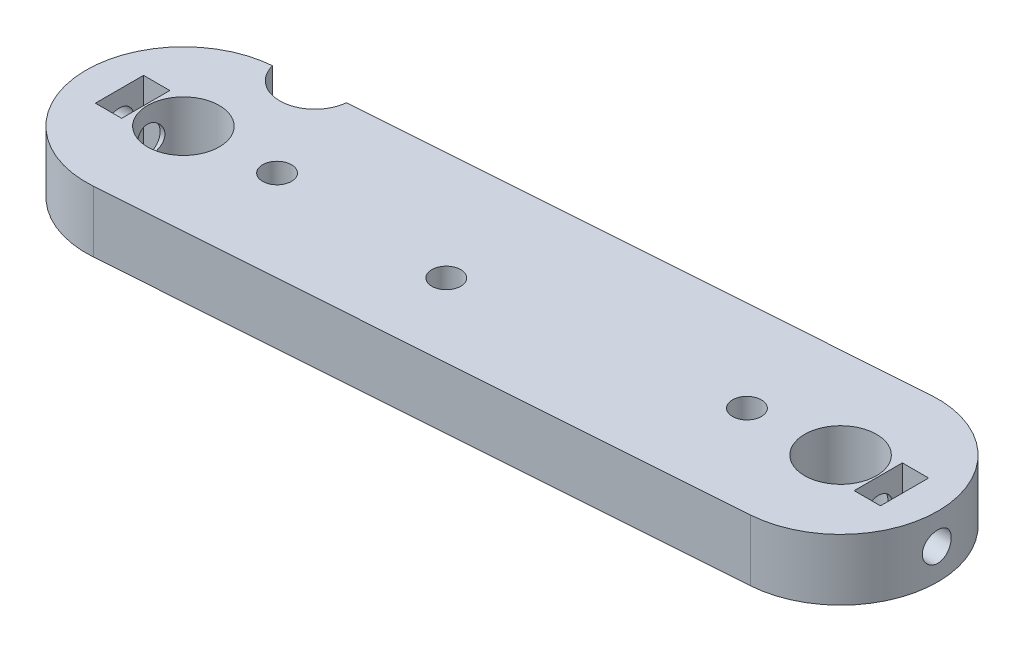
from build123d import *

# Parameters (mm, degrees)
ESBO_O2_R                  = 4.1
ESBO_O2_R_2                = 1.65
ESBO_O2_W                  = 3
ESBO_O2_H                  = 5.5
RESSALTO_EXTRUS_O1_DEPTH   = 7
ESBO_O3_W                  = 117.766713874
ESBO_O3_H                  = 105.694955048
CORTE_EXTRUS_O1_DEPTH      = 1
CORTE_EXTRUS_O1_DEPTH_BACK = 8
ESBO_O4_R                  = 1.65
CORTE_EXTRUS_O2_DEPTH      = 7.8
CORTE_EXTRUS_O2_DEPTH_BACK = 2
ESBO_O5_R                  = 1.65
CORTE_EXTRUS_O3_DEPTH      = 10
CORTE_EXTRUS_O3_DEPTH_BACK = 2
ESBO_O6_R                  = 4
CORTE_EXTRUS_O4_DEPTH      = 1.0000001
CORTE_EXTRUS_O4_DEPTH_BACK = 8.0000001


with BuildPart() as part:
    # Esboço2 → Ressalto-extrusão1 (new body)
    with BuildSketch(Plane(origin=(0, 0, 0), x_dir=(1, 0, 0), z_dir=(0, 1, 0))):
        with BuildLine():
            Line((-0.790842255, 46.071791568), (69.209157745, 51.071791568))
            ThreePointArc((69.209157745, 51.071791568), (77.564114323, 48.123679863), (81.1, 40))
            Line((81.1, 40), (81.1, -40))
            ThreePointArc((81.1, -40), (77.564114323, -48.123679863), (69.209157745, -51.071791568))
            Line((69.209157745, -51.071791568), (-0.790842255, -46.071791568))
            ThreePointArc((-0.790842255, -46.071791568), (-8.123679863, -42.564114323), (-11.1, -35))
            Line((-11.1, -35), (-11.1, 35))
            ThreePointArc((-11.1, 35), (-8.123679863, 42.564114323), (-0.790842255, 46.071791568))
        make_face()
        with Locations((0, 35)):
            Circle(ESBO_O2_R, mode=Mode.SUBTRACT)
        with Locations((70, 40)):
            Circle(ESBO_O2_R, mode=Mode.SUBTRACT)
        with Locations((70, -40)):
            Circle(ESBO_O2_R, mode=Mode.SUBTRACT)
        with Locations((0, -35)):
            Circle(ESBO_O2_R, mode=Mode.SUBTRACT)
        with Locations((9.974586998, 35.7124705)):
            Circle(ESBO_O2_R_2, mode=Mode.SUBTRACT)
        with Locations((60.025413002, 39.2875295)):
            Circle(ESBO_O2_R_2, mode=Mode.SUBTRACT)
        with Locations((9.974586998, -35.7124705)):
            Circle(ESBO_O2_R_2, mode=Mode.SUBTRACT)
        with Locations((60.025413002, -39.2875295)):
            Circle(ESBO_O2_R_2, mode=Mode.SUBTRACT)
        with Locations((30, 35)):
            Circle(ESBO_O2_R_2, mode=Mode.SUBTRACT)
        with Locations((30, -35)):
            Circle(ESBO_O2_R_2, mode=Mode.SUBTRACT)
        with Locations((-5.8, 35)):
            Rectangle(ESBO_O2_W, ESBO_O2_H, mode=Mode.SUBTRACT)
        with Locations((75.8, 40)):
            Rectangle(ESBO_O2_W, ESBO_O2_H, mode=Mode.SUBTRACT)
        with Locations((75.8, -40)):
            Rectangle(ESBO_O2_W, ESBO_O2_H, mode=Mode.SUBTRACT)
        with Locations((-5.8, -35)):
            Rectangle(ESBO_O2_W, ESBO_O2_H, mode=Mode.SUBTRACT)
    extrude(amount=RESSALTO_EXTRUS_O1_DEPTH)

    # Esboço3 → Corte-extrusão1 (cut, two sides)
    with BuildSketch(Plane(origin=(0, 7, 0), x_dir=(1, 0, 0), z_dir=(0, 1, 0))) as corte_extrus_o1_sk:
        with Locations((40.401748759, 0)):
            Rectangle(ESBO_O3_W, ESBO_O3_H)
        with BuildLine():
            Line((0.790842255, 23.928208432), (70.790842255, 28.928208432))
            ThreePointArc((70.790842255, 28.928208432), (81.071791568, 40.790842255), (69.209157745, 51.071791568))
            Line((69.209157745, 51.071791568), (-0.790842255, 46.071791568))
            ThreePointArc((-0.790842255, 46.071791568), (-11.071791568, 34.209157745), (0.790842255, 23.928208432))
        make_face(mode=Mode.SUBTRACT)
    extrude(amount=CORTE_EXTRUS_O1_DEPTH, mode=Mode.SUBTRACT)
    extrude(corte_extrus_o1_sk.sketch, amount=-CORTE_EXTRUS_O1_DEPTH_BACK, mode=Mode.SUBTRACT)

    # Esboço4 → Corte-extrusão2 (cut, two sides)
    with BuildSketch(Plane.ZY.offset(4.3)) as corte_extrus_o2_sk:
        with Locations((-35, 3.5)):
            Circle(ESBO_O4_R)
    extrude(amount=CORTE_EXTRUS_O2_DEPTH, mode=Mode.SUBTRACT)
    extrude(corte_extrus_o2_sk.sketch, amount=-CORTE_EXTRUS_O2_DEPTH_BACK, mode=Mode.SUBTRACT)

    # Esboço5 → Corte-extrusão3 (cut, two sides)
    with BuildSketch(Plane(origin=(74.3, 0, 0), x_dir=(0, 0, -1), z_dir=(1, 0, 0))) as corte_extrus_o3_sk:
        with Locations((40, 3.5)):
            Circle(ESBO_O5_R)
    extrude(amount=CORTE_EXTRUS_O3_DEPTH, mode=Mode.SUBTRACT)
    extrude(corte_extrus_o3_sk.sketch, amount=-CORTE_EXTRUS_O3_DEPTH_BACK, mode=Mode.SUBTRACT)

    # Esboço6 → Corte-extrusão4 (cut, two sides)
    with BuildSketch(Plane(origin=(0, 7, 0), x_dir=(1, 0, 0), z_dir=(0, 1, 0))) as corte_extrus_o4_sk:
        with Locations((3, 47)):
            Circle(ESBO_O6_R)
    extrude(amount=CORTE_EXTRUS_O4_DEPTH, mode=Mode.SUBTRACT)
    extrude(corte_extrus_o4_sk.sketch, amount=-CORTE_EXTRUS_O4_DEPTH_BACK, mode=Mode.SUBTRACT)


solid = part.part
